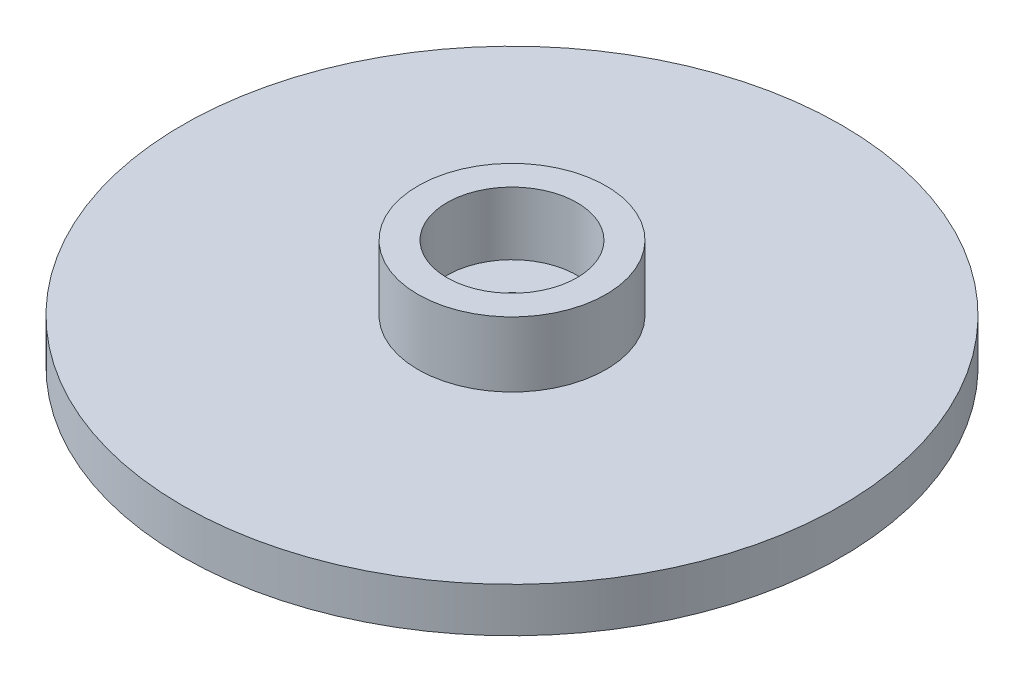
from build123d import *


with BuildPart() as part:
    # Sketch1 → Revolve1 (revolve)
    with BuildSketch(Plane.XY):
        Polygon((0.889, 1.6764), (0.889, 0), (11.8364, 0), (11.8364, 1.6002), (3.3782, 1.6002), (3.3782, 3.937), (2.3368, 3.937), (2.3368, 1.6764), align=None)
    revolve(axis=Axis((0, 1.6764, 0), (0, -1, 0)))


solid = part.part
